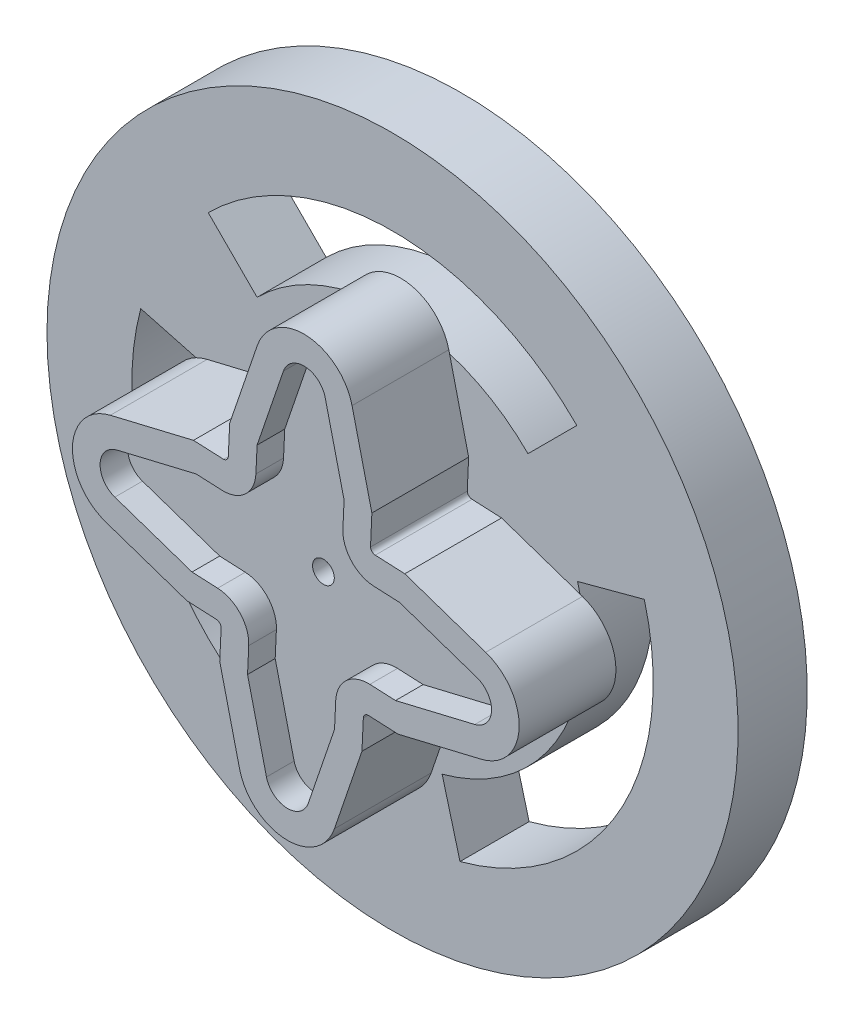
from build123d import *

# Parameters (mm, degrees)
EXTRUDE_THIN1_DEPTH = 2.54
EXTRUDE_THIN2_DEPTH = 6.35
BOSS_EXTRUDE1_DEPTH = 6.35
SKETCH2_R           = 31.75
BOSS_EXTRUDE2_DEPTH = 6.35
CUT_EXTRUDE1_DEPTH  = 6.35
SKETCH4_R           = 1
CUT_EXTRUDE2_DEPTH  = 16.24
CHAMFER2_SIZE       = 2.54


with BuildPart() as part:
    # Sketch1 → Extrude-Thin1 (new body)
    with BuildSketch(Plane.XY):
        with BuildLine():
            Line((-17.033098657, 5.209024178), (-9.398237952, 7.030294761))
            Line((-9.398237952, 7.030294761), (-6.628258472, 6.90375806))
            ThreePointArc((-6.628258472, 6.90375806), (-6.331733624, 7.041258836), (-6.201391634, 7.340999415))
            Line((-6.201391634, 7.340999415), (-6.07380581, 10.055084177))
            Line((-6.07380581, 10.055084177), (-3.543785692, 17.487046073))
            ThreePointArc((-3.543785692, 17.487046073), (0.967191009, 20.558965329), (5.170097171, 17.077417038))
            Line((5.170097171, 17.077417038), (6.991367754, 9.442556334))
            Line((6.991367754, 9.442556334), (6.864831053, 6.672576854))
            ThreePointArc((6.864831053, 6.672576854), (7.002331829, 6.376052005), (7.302072408, 6.245710016))
            Line((7.302072408, 6.245710016), (10.01615717, 6.118124192))
            Line((10.01615717, 6.118124192), (17.448119066, 3.588104073))
            ThreePointArc((17.448119066, 3.588104073), (20.520038322, -0.922872627), (17.038490031, -5.125778789))
            Line((17.038490031, -5.125778789), (9.401960539, -6.947447456))
            Line((9.401960539, -6.947447456), (6.687875777, -6.819861633))
            ThreePointArc((6.687875777, -6.819861633), (6.356638909, -6.939170255), (6.206783009, -7.257754026))
            Line((6.206783009, -7.257754026), (6.079197185, -9.971838788))
            Line((6.079197185, -9.971838788), (3.549177067, -17.403800684))
            ThreePointArc((3.549177067, -17.403800684), (-0.961799634, -20.47571994), (-5.164705796, -16.99417165))
            Line((-5.164705796, -16.99417165), (-6.986374463, -9.357642157))
            Line((-6.986374463, -9.357642157), (-6.85878864, -6.643557395))
            ThreePointArc((-6.85878864, -6.643557395), (-6.978097262, -6.312320527), (-7.296681033, -6.162464627))
            Line((-7.296681033, -6.162464627), (-10.010765795, -6.034878804))
            Line((-10.010765795, -6.034878804), (-17.442727691, -3.504858685))
            ThreePointArc((-17.442727691, -3.504858685), (-20.514646947, 1.006118016), (-17.033098657, 5.209024178))
        make_face()
        with BuildLine():
            Line((-16.443727069, 2.738347928), (-9.156812059, 4.476617225))
            Line((-9.156812059, 4.476617225), (-6.660884215, 4.362599602))
            ThreePointArc((-6.660884215, 4.362599602), (-4.589968036, 5.192045254), (-3.66419347, 7.221728815))
            Line((-3.66419347, 7.221728815), (-3.553485102, 9.576785873))
            Line((-3.553485102, 9.576785873), (-1.139293996, 16.66849877))
            ThreePointArc((-1.139293996, 16.66849877), (0.847920409, 18.021767165), (2.699420921, 16.488045451))
            Line((2.699420921, 16.488045451), (4.437690218, 9.201130441))
            Line((4.437690218, 9.201130441), (4.323672595, 6.705202597))
            ThreePointArc((4.323672595, 6.705202597), (5.153118247, 4.634286418), (7.182801808, 3.708511852))
            Line((7.182801808, 3.708511852), (9.537858866, 3.597803484))
            Line((9.537858866, 3.597803484), (16.629571763, 1.183612378))
            ThreePointArc((16.629571763, 1.183612378), (17.982840158, -0.803602027), (16.449118444, -2.655102539))
            Line((16.449118444, -2.655102539), (9.162203434, -4.393371836))
            Line((9.162203434, -4.393371836), (6.807146377, -4.282663469))
            ThreePointArc((6.807146377, -4.282663469), (4.646905931, -5.060763178), (3.669584845, -7.138483427))
            Line((3.669584845, -7.138483427), (3.558876477, -9.493540484))
            Line((3.558876477, -9.493540484), (1.144685371, -16.585253381))
            ThreePointArc((1.144685371, -16.585253381), (-0.842529034, -17.938521776), (-2.694029546, -16.404800062))
            Line((-2.694029546, -16.404800062), (-4.432298843, -9.117885052))
            Line((-4.432298843, -9.117885052), (-4.321590476, -6.762827995))
            ThreePointArc((-4.321590476, -6.762827995), (-5.099690185, -4.60258755), (-7.177410434, -3.625266463))
            Line((-7.177410434, -3.625266463), (-9.532467491, -3.514558095))
            Line((-9.532467491, -3.514558095), (-16.624180388, -1.100366989))
            ThreePointArc((-16.624180388, -1.100366989), (-17.977448783, 0.886847416), (-16.443727069, 2.738347928))
        make_face(mode=Mode.SUBTRACT)
    extrude(amount=EXTRUDE_THIN1_DEPTH)

    # Sketch1_5 → Extrude-Thin2 (add)
    with BuildSketch(Plane.XY):
        with BuildLine():
            Line((-17.033098657, 5.209024178), (-9.398237952, 7.030294761))
            Line((-9.398237952, 7.030294761), (-6.628258472, 6.90375806))
            ThreePointArc((-6.628258472, 6.90375806), (-6.331733624, 7.041258836), (-6.201391634, 7.340999415))
            Line((-6.201391634, 7.340999415), (-6.07380581, 10.055084177))
            Line((-6.07380581, 10.055084177), (-3.543785692, 17.487046073))
            ThreePointArc((-3.543785692, 17.487046073), (0.967191009, 20.558965329), (5.170097171, 17.077417038))
            Line((5.170097171, 17.077417038), (6.991367754, 9.442556334))
            Line((6.991367754, 9.442556334), (6.864831053, 6.672576854))
            ThreePointArc((6.864831053, 6.672576854), (7.002331829, 6.376052005), (7.302072408, 6.245710016))
            Line((7.302072408, 6.245710016), (10.01615717, 6.118124192))
            Line((10.01615717, 6.118124192), (17.448119066, 3.588104073))
            ThreePointArc((17.448119066, 3.588104073), (20.520038322, -0.922872627), (17.038490031, -5.125778789))
            Line((17.038490031, -5.125778789), (9.401960539, -6.947447456))
            Line((9.401960539, -6.947447456), (6.687875777, -6.819861633))
            ThreePointArc((6.687875777, -6.819861633), (6.356638909, -6.939170255), (6.206783009, -7.257754026))
            Line((6.206783009, -7.257754026), (6.079197185, -9.971838788))
            Line((6.079197185, -9.971838788), (3.549177067, -17.403800684))
            ThreePointArc((3.549177067, -17.403800684), (-0.961799634, -20.47571994), (-5.164705796, -16.99417165))
            Line((-5.164705796, -16.99417165), (-6.986374463, -9.357642157))
            Line((-6.986374463, -9.357642157), (-6.85878864, -6.643557395))
            ThreePointArc((-6.85878864, -6.643557395), (-6.978097262, -6.312320527), (-7.296681033, -6.162464627))
            Line((-7.296681033, -6.162464627), (-10.010765795, -6.034878804))
            Line((-10.010765795, -6.034878804), (-17.442727691, -3.504858685))
            ThreePointArc((-17.442727691, -3.504858685), (-20.514646947, 1.006118016), (-17.033098657, 5.209024178))
        make_face()
        with BuildLine():
            Line((-16.443727069, 2.738347928), (-9.156812059, 4.476617225))
            Line((-9.156812059, 4.476617225), (-6.660884215, 4.362599602))
            ThreePointArc((-6.660884215, 4.362599602), (-4.589968036, 5.192045254), (-3.66419347, 7.221728815))
            Line((-3.66419347, 7.221728815), (-3.553485102, 9.576785873))
            Line((-3.553485102, 9.576785873), (-1.139293996, 16.66849877))
            ThreePointArc((-1.139293996, 16.66849877), (0.847920409, 18.021767165), (2.699420921, 16.488045451))
            Line((2.699420921, 16.488045451), (4.437690218, 9.201130441))
            Line((4.437690218, 9.201130441), (4.323672595, 6.705202597))
            ThreePointArc((4.323672595, 6.705202597), (5.153118247, 4.634286418), (7.182801808, 3.708511852))
            Line((7.182801808, 3.708511852), (9.537858866, 3.597803484))
            Line((9.537858866, 3.597803484), (16.629571763, 1.183612378))
            ThreePointArc((16.629571763, 1.183612378), (17.982840158, -0.803602027), (16.449118444, -2.655102539))
            Line((16.449118444, -2.655102539), (9.162203434, -4.393371836))
            Line((9.162203434, -4.393371836), (6.807146377, -4.282663469))
            ThreePointArc((6.807146377, -4.282663469), (4.646905931, -5.060763178), (3.669584845, -7.138483427))
            Line((3.669584845, -7.138483427), (3.558876477, -9.493540484))
            Line((3.558876477, -9.493540484), (1.144685371, -16.585253381))
            ThreePointArc((1.144685371, -16.585253381), (-0.842529034, -17.938521776), (-2.694029546, -16.404800062))
            Line((-2.694029546, -16.404800062), (-4.432298843, -9.117885052))
            Line((-4.432298843, -9.117885052), (-4.321590476, -6.762827995))
            ThreePointArc((-4.321590476, -6.762827995), (-5.099690185, -4.60258755), (-7.177410434, -3.625266463))
            Line((-7.177410434, -3.625266463), (-9.532467491, -3.514558095))
            Line((-9.532467491, -3.514558095), (-16.624180388, -1.100366989))
            ThreePointArc((-16.624180388, -1.100366989), (-17.977448783, 0.886847416), (-16.443727069, 2.738347928))
        make_face(mode=Mode.SUBTRACT)
    extrude(amount=-EXTRUDE_THIN2_DEPTH)

    # Sketch1_6 → Boss-Extrude1 (add)
    with BuildSketch(Plane.XY):
        with BuildLine():
            ThreePointArc((-16.624180388, -1.100366989), (-17.977448783, 0.886847416), (-16.443727069, 2.738347928))
            Line((-16.443727069, 2.738347928), (-9.156812059, 4.476617225))
            Line((-9.156812059, 4.476617225), (-6.660884215, 4.362599602))
            ThreePointArc((-6.660884215, 4.362599602), (-4.589968036, 5.192045254), (-3.66419347, 7.221728815))
            Line((-3.66419347, 7.221728815), (-3.553485102, 9.576785873))
            Line((-3.553485102, 9.576785873), (-1.139293996, 16.66849877))
            ThreePointArc((-1.139293996, 16.66849877), (0.847920409, 18.021767165), (2.699420921, 16.488045451))
            Line((2.699420921, 16.488045451), (4.437690218, 9.201130441))
            Line((4.437690218, 9.201130441), (4.323672595, 6.705202597))
            ThreePointArc((4.323672595, 6.705202597), (5.153118247, 4.634286418), (7.182801808, 3.708511852))
            Line((7.182801808, 3.708511852), (9.537858866, 3.597803484))
            Line((9.537858866, 3.597803484), (16.629571763, 1.183612378))
            ThreePointArc((16.629571763, 1.183612378), (17.982840158, -0.803602027), (16.449118444, -2.655102539))
            Line((16.449118444, -2.655102539), (9.162203434, -4.393371836))
            Line((9.162203434, -4.393371836), (6.807146377, -4.282663469))
            ThreePointArc((6.807146377, -4.282663469), (4.646905931, -5.060763178), (3.669584845, -7.138483427))
            Line((3.669584845, -7.138483427), (3.558876477, -9.493540484))
            Line((3.558876477, -9.493540484), (1.144685371, -16.585253381))
            ThreePointArc((1.144685371, -16.585253381), (-0.842529034, -17.938521776), (-2.694029546, -16.404800062))
            Line((-2.694029546, -16.404800062), (-4.432298843, -9.117885052))
            Line((-4.432298843, -9.117885052), (-4.321590476, -6.762827995))
            ThreePointArc((-4.321590476, -6.762827995), (-5.099690185, -4.60258755), (-7.177410434, -3.625266463))
            Line((-7.177410434, -3.625266463), (-9.532467491, -3.514558095))
            Line((-9.532467491, -3.514558095), (-16.624180388, -1.100366989))
        make_face()
    extrude(amount=-BOSS_EXTRUDE1_DEPTH)

    # Sketch2 → Boss-Extrude2 (add)
    with BuildSketch(Plane(origin=(0, 0, -6.35), x_dir=(-1, 0, 0), z_dir=(0, 0, -1))):
        Circle(SKETCH2_R)
    extrude(amount=BOSS_EXTRUDE2_DEPTH)

    # Sketch3 → Cut-Extrude1 (cut)
    with BuildSketch(Plane(origin=(0, 0, -12.7), x_dir=(-1, 0, 0), z_dir=(0, 0, -1))):
        with BuildLine():
            Line((-16.934288716, 16.934288716), (-12.444160656, 12.444160656))
            ThreePointArc((-12.444160656, 12.444160656), (0, 17.598700771), (12.444160656, 12.444160656))
            Line((12.444160656, 12.444160656), (16.934288716, 16.934288716))
            ThreePointArc((16.934288716, 16.934288716), (0, 23.948700771), (-16.934288716, 16.934288716))
        make_face()
        with BuildLine():
            Line((6.198379865, -23.132668581), (4.554878929, -16.999039584))
            ThreePointArc((4.554878929, -16.999039584), (15.240921942, -8.799350386), (16.999039584, 4.554878929))
            Line((16.999039584, 4.554878929), (23.132668581, 6.198379865))
            ThreePointArc((23.132668581, 6.198379865), (20.740183256, -11.974350386), (6.198379865, -23.132668581))
        make_face()
        with BuildLine():
            Line((-23.132668581, 6.198379865), (-16.999039584, 4.554878929))
            ThreePointArc((-16.999039584, 4.554878929), (-15.240921942, -8.799350386), (-4.554878929, -16.999039584))
            Line((-4.554878929, -16.999039584), (-6.198379865, -23.132668581))
            ThreePointArc((-6.198379865, -23.132668581), (-20.740183256, -11.974350386), (-23.132668581, 6.198379865))
        make_face()
    extrude(amount=-CUT_EXTRUDE1_DEPTH, mode=Mode.SUBTRACT)

    # Sketch4 → Cut-Extrude2 (cut, through all)
    with BuildSketch(Plane(origin=(0, 0, -12.7), x_dir=(-1, 0, 0), z_dir=(0, 0, -1))):
        Circle(SKETCH4_R)
    extrude(amount=-CUT_EXTRUDE2_DEPTH, mode=Mode.SUBTRACT)

    # Chamfer2
    chamfer2_edges = [part.edges().sort_by_distance(p)[0] for p in [
        (1, 0, -12.7),
    ]]
    chamfer(chamfer2_edges, length=CHAMFER2_SIZE)


solid = part.part
